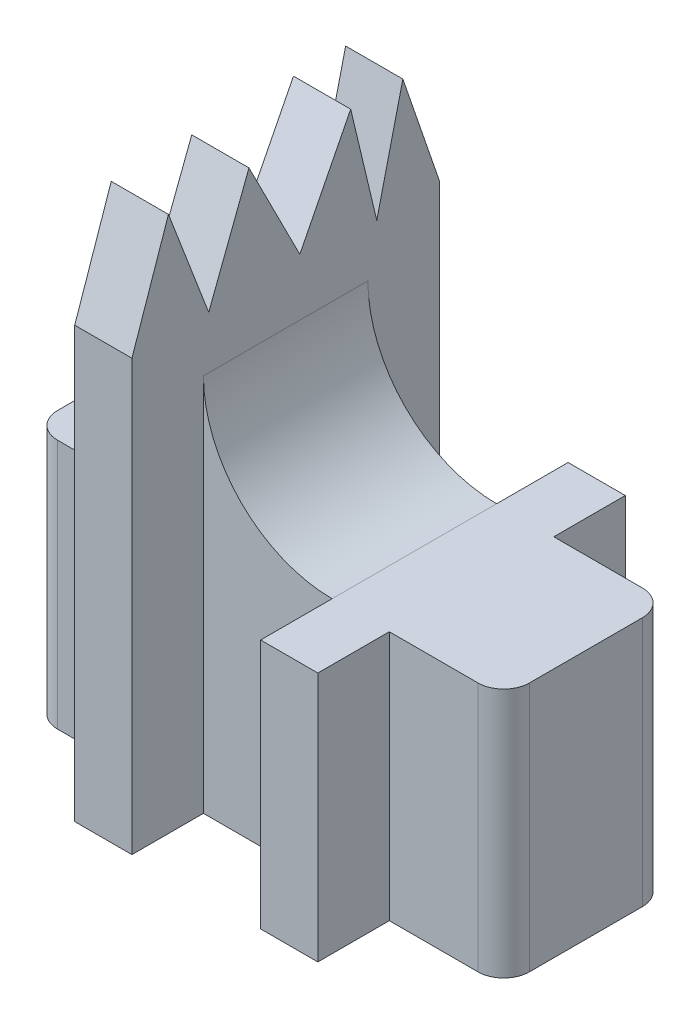
from build123d import *

# Parameters (mm, degrees)
SKETCH1_W           = 4
SKETCH1_H           = 5.75
SKETCH1_W_2         = 2
SKETCH1_H_2         = 2.5
SKETCH1_W_3         = 2.25
BOSS_EXTRUDE1_DEPTH = 8.75
FILLET1_R           = 0.9
SKETCH2_W           = 2
SKETCH2_H           = 10.75
BOSS_EXTRUDE2_DEPTH = 10
CUT_EXTRUDE1_DEPTH  = 13.5
FILLET2_R           = 4.5


with BuildPart() as part:
    # Sketch1 → Boss-Extrude1 (new body)
    with BuildSketch(Plane(origin=(0, 0, 0), x_dir=(1, 0, 0), z_dir=(0, 1, 0))):
        with Locations((-6.25, 0)):
            Rectangle(SKETCH1_W, SKETCH1_H)
        with Locations((-3.25, 4.125)):
            Rectangle(SKETCH1_W_2, SKETCH1_H_2)
        with Locations((-3.25, -4.125)):
            Rectangle(SKETCH1_W_2, SKETCH1_H_2)
        with Locations((-3.25, 0)):
            Rectangle(SKETCH1_W_2, SKETCH1_H)
        with Locations((-1.125, 0)):
            Rectangle(SKETCH1_W_3, SKETCH1_H)
        with Locations((1.125, 0)):
            Rectangle(SKETCH1_W_3, SKETCH1_H)
        with Locations((3.25, 4.125)):
            Rectangle(SKETCH1_W_2, SKETCH1_H_2)
        with Locations((6.25, 0)):
            Rectangle(SKETCH1_W, SKETCH1_H)
        with Locations((3.25, 0)):
            Rectangle(SKETCH1_W_2, SKETCH1_H)
        with Locations((3.25, -4.125)):
            Rectangle(SKETCH1_W_2, SKETCH1_H_2)
    extrude(amount=BOSS_EXTRUDE1_DEPTH)

    # Fillet1
    fillet1_edges = [part.edges().sort_by_distance(p)[0] for p in [
        (-8.25, 4.375, 2.875),
        (-8.25, 4.375, -2.875),
        (8.25, 4.375, -2.875),
        (8.25, 4.375, 2.875),
    ]]
    fillet(fillet1_edges, radius=FILLET1_R)

    # Sketch2 → Boss-Extrude2 (add)
    with BuildSketch(Plane(origin=(0, 8.75, 0), x_dir=(1, 0, 0), z_dir=(0, 1, 0))):
        with Locations((-3.25, 0)):
            Rectangle(SKETCH2_W, SKETCH2_H)
    extrude(amount=BOSS_EXTRUDE2_DEPTH)

    # Sketch3 → Cut-Extrude1 (cut, through all)
    with BuildSketch(Plane.ZY.offset(4.25)):
        Polygon((-5.375, 18.75), (-5.375, 15.031688137), (-4.097886003, 18.75), align=None)
        Polygon((-2.273593829, 18.75), (-4.097886003, 18.75), (-3.185739916, 14.925754612), align=None)
        Polygon((1.282681443, 18.75), (-2.273593829, 18.75), (-0.495456193, 15.243564513), align=None)
        Polygon((4.097886003, 18.75), (1.282681443, 18.75), (2.690283723, 15.079098327), align=None)
        Polygon((5.375, 18.75), (4.097886003, 18.75), (5.375, 15.031688137), align=None)
    extrude(amount=-CUT_EXTRUDE1_DEPTH, mode=Mode.SUBTRACT)

    # Fillet2
    fillet2_edges = [part.edges().sort_by_distance(p)[0] for p in [
        (-2.25, 8.75, 0),
    ]]
    fillet(fillet2_edges, radius=FILLET2_R)


solid = part.part
